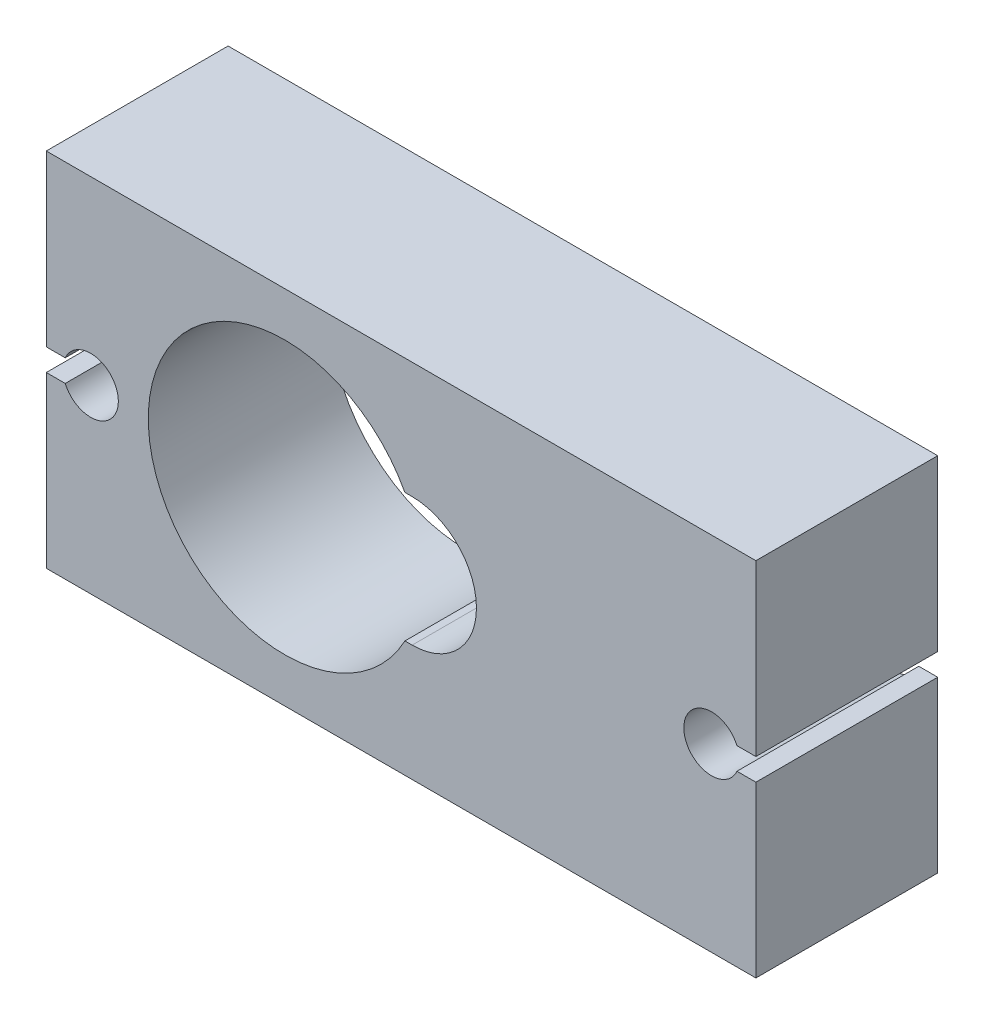
from build123d import *

# Parameters (mm, degrees)
BOSS_EXTRUDE1_DEPTH = 8.2


with BuildPart() as part:
    # Sketch1 → Boss-Extrude1 (new body)
    with BuildSketch(Plane.XY):
        with BuildLine():
            Line((5.002809822, -2.4), (-27, -2.4))
            Line((-27, -2.4), (-27, 5.24803322))
            Line((-27, 5.24803322), (-26.145643924, 5.24803322))
            ThreePointArc((-26.145643924, 5.24803322), (-23.75, 5.74803322), (-26.145643924, 6.24803322))
            Line((-26.145643924, 6.24803322), (-27, 6.24803322))
            Line((-27, 6.24803322), (-27, 13.9))
            Line((-27, 13.9), (5.002809822, 13.9))
            Line((5.002809822, 13.9), (5.002809822, 6.24803322))
            Line((5.002809822, 6.24803322), (4.148453745, 6.24803322))
            ThreePointArc((4.148453745, 6.24803322), (1.752809822, 5.74803322), (4.148453745, 5.24803322))
            Line((4.148453745, 5.24803322), (5.002809822, 5.24803322))
            Line((5.002809822, 5.24803322), (5.002809822, -2.4))
        make_face()
        with BuildLine():
            Line((-10.5, 8.65), (-10.826670764, 8.65))
            ThreePointArc((-10.826670764, 8.65), (-22.4, 5.75), (-10.826670764, 2.85))
            Line((-10.826670764, 2.85), (-10.5, 2.85))
            ThreePointArc((-10.5, 2.85), (-7.6, 5.75), (-10.5, 8.65))
        make_face(mode=Mode.SUBTRACT)
    extrude(amount=BOSS_EXTRUDE1_DEPTH)


solid = part.part
